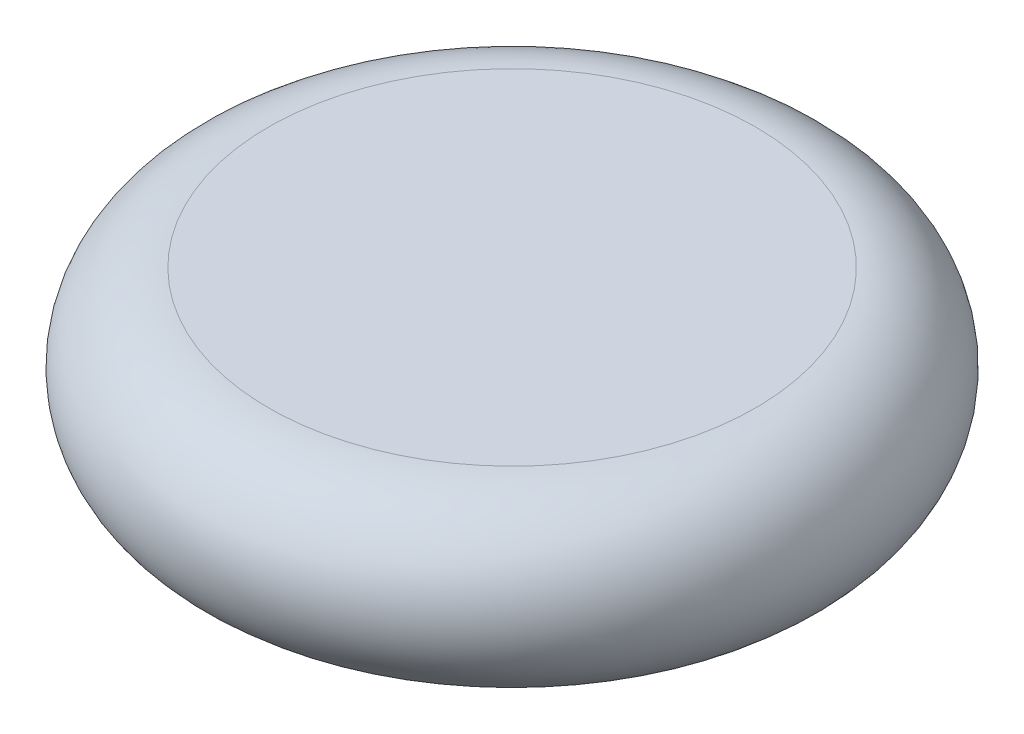
from build123d import *


with BuildPart() as part:
    # Sketch1 → Revolve1 (revolve)
    with BuildSketch(Plane(origin=(0, 0, 0), x_dir=(0, 0, -1), z_dir=(1, 0, 0))):
        with BuildLine():
            Line((0, 0), (20.632220903, 0))
            ThreePointArc((20.632220903, 0), (27.94, 7.307779097), (20.632220903, 14.615558195))
            Line((20.632220903, 14.615558195), (0, 14.615558195))
            Line((0, 14.615558195), (0, 0))
        make_face()
    revolve(axis=Axis((0, 0, 0), (0, 1, 0)))


solid = part.part
